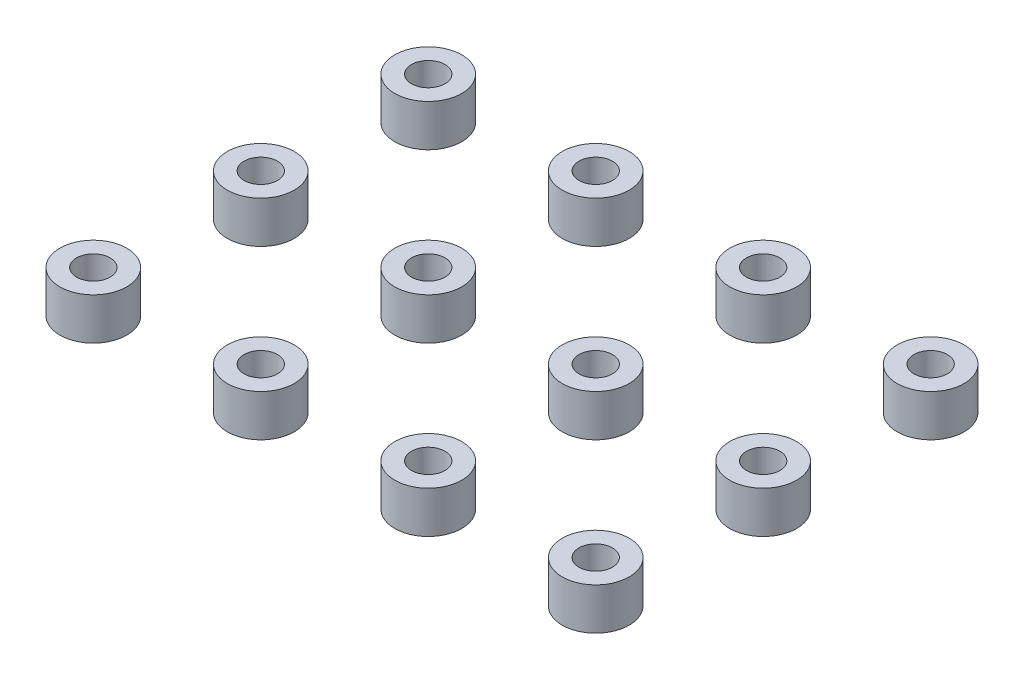
from build123d import *

# Parameters (mm, degrees)
SKETCH1_R              = 4
SKETCH1_R_2            = 2
BOSS_EXTRUDE1_DEPTH    = 5
BOSS_EXTRUDE1_2_DEPTH  = 5
BOSS_EXTRUDE1_3_DEPTH  = 5
BOSS_EXTRUDE1_4_DEPTH  = 5
BOSS_EXTRUDE1_5_DEPTH  = 5
BOSS_EXTRUDE1_6_DEPTH  = 5
BOSS_EXTRUDE1_7_DEPTH  = 5
BOSS_EXTRUDE1_8_DEPTH  = 5
BOSS_EXTRUDE1_9_DEPTH  = 5
BOSS_EXTRUDE1_10_DEPTH = 5
BOSS_EXTRUDE1_11_DEPTH = 5
BOSS_EXTRUDE1_12_DEPTH = 5


with BuildPart() as part:
    # Sketch1 → Boss-Extrude1 (new body)
    with BuildSketch(Plane(origin=(0, 0, 0), x_dir=(1, 0, 0), z_dir=(0, 1, 0))):
        with Locations((-30, 30)):
            Circle(SKETCH1_R)
        with Locations((-30, 30)):
            Circle(SKETCH1_R_2, mode=Mode.SUBTRACT)
    extrude(amount=BOSS_EXTRUDE1_DEPTH)


with BuildPart() as body_2:
    # Sketch1 → Boss-Extrude1 2 (new body)
    with BuildSketch(Plane(origin=(0, 0, 0), x_dir=(1, 0, 0), z_dir=(0, 1, 0))):
        with Locations((-10, 30)):
            Circle(SKETCH1_R)
        with Locations((-10, 30)):
            Circle(SKETCH1_R_2, mode=Mode.SUBTRACT)
    extrude(amount=BOSS_EXTRUDE1_2_DEPTH)


with BuildPart() as body_3:
    # Sketch1 → Boss-Extrude1 3 (new body)
    with BuildSketch(Plane(origin=(0, 0, 0), x_dir=(1, 0, 0), z_dir=(0, 1, 0))):
        with Locations((10, 30)):
            Circle(SKETCH1_R)
        with Locations((10, 30)):
            Circle(SKETCH1_R_2, mode=Mode.SUBTRACT)
    extrude(amount=BOSS_EXTRUDE1_3_DEPTH)


with BuildPart() as body_4:
    # Sketch1 → Boss-Extrude1 4 (new body)
    with BuildSketch(Plane(origin=(0, 0, 0), x_dir=(1, 0, 0), z_dir=(0, 1, 0))):
        with Locations((30, 30)):
            Circle(SKETCH1_R)
        with Locations((30, 30)):
            Circle(SKETCH1_R_2, mode=Mode.SUBTRACT)
    extrude(amount=BOSS_EXTRUDE1_4_DEPTH)


with BuildPart() as body_5:
    # Sketch1 → Boss-Extrude1 5 (new body)
    with BuildSketch(Plane(origin=(0, 0, 0), x_dir=(1, 0, 0), z_dir=(0, 1, 0))):
        with Locations((-10, 50)):
            Circle(SKETCH1_R)
        with Locations((-10, 50)):
            Circle(SKETCH1_R_2, mode=Mode.SUBTRACT)
    extrude(amount=BOSS_EXTRUDE1_5_DEPTH)


with BuildPart() as body_6:
    # Sketch1 → Boss-Extrude1 6 (new body)
    with BuildSketch(Plane(origin=(0, 0, 0), x_dir=(1, 0, 0), z_dir=(0, 1, 0))):
        with Locations((10, 50)):
            Circle(SKETCH1_R)
        with Locations((10, 50)):
            Circle(SKETCH1_R_2, mode=Mode.SUBTRACT)
    extrude(amount=BOSS_EXTRUDE1_6_DEPTH)


with BuildPart() as body_7:
    # Sketch1 → Boss-Extrude1 7 (new body)
    with BuildSketch(Plane(origin=(0, 0, 0), x_dir=(1, 0, 0), z_dir=(0, 1, 0))):
        with Locations((30, 50)):
            Circle(SKETCH1_R)
        with Locations((30, 50)):
            Circle(SKETCH1_R_2, mode=Mode.SUBTRACT)
    extrude(amount=BOSS_EXTRUDE1_7_DEPTH)


with BuildPart() as body_8:
    # Sketch1 → Boss-Extrude1 8 (new body)
    with BuildSketch(Plane(origin=(0, 0, 0), x_dir=(1, 0, 0), z_dir=(0, 1, 0))):
        with Locations((-10, 70)):
            Circle(SKETCH1_R)
        with Locations((-10, 70)):
            Circle(SKETCH1_R_2, mode=Mode.SUBTRACT)
    extrude(amount=BOSS_EXTRUDE1_8_DEPTH)


with BuildPart() as body_9:
    # Sketch1 → Boss-Extrude1 9 (new body)
    with BuildSketch(Plane(origin=(0, 0, 0), x_dir=(1, 0, 0), z_dir=(0, 1, 0))):
        with Locations((10, 70)):
            Circle(SKETCH1_R)
        with Locations((10, 70)):
            Circle(SKETCH1_R_2, mode=Mode.SUBTRACT)
    extrude(amount=BOSS_EXTRUDE1_9_DEPTH)


with BuildPart() as body_10:
    # Sketch1 → Boss-Extrude1 10 (new body)
    with BuildSketch(Plane(origin=(0, 0, 0), x_dir=(1, 0, 0), z_dir=(0, 1, 0))):
        with Locations((30, 70)):
            Circle(SKETCH1_R)
        with Locations((30, 70)):
            Circle(SKETCH1_R_2, mode=Mode.SUBTRACT)
    extrude(amount=BOSS_EXTRUDE1_10_DEPTH)


with BuildPart() as body_11:
    # Sketch1 → Boss-Extrude1 11 (new body)
    with BuildSketch(Plane(origin=(0, 0, 0), x_dir=(1, 0, 0), z_dir=(0, 1, 0))):
        with Locations((-30, 50)):
            Circle(SKETCH1_R)
        with Locations((-30, 50)):
            Circle(SKETCH1_R_2, mode=Mode.SUBTRACT)
    extrude(amount=BOSS_EXTRUDE1_11_DEPTH)


with BuildPart() as body_12:
    # Sketch1 → Boss-Extrude1 12 (new body)
    with BuildSketch(Plane(origin=(0, 0, 0), x_dir=(1, 0, 0), z_dir=(0, 1, 0))):
        with Locations((-30, 70)):
            Circle(SKETCH1_R)
        with Locations((-30, 70)):
            Circle(SKETCH1_R_2, mode=Mode.SUBTRACT)
    extrude(amount=BOSS_EXTRUDE1_12_DEPTH)


solid = Compound([part.part, body_2.part, body_3.part, body_4.part, body_5.part, body_6.part, body_7.part, body_8.part, body_9.part, body_10.part, body_11.part, body_12.part])
